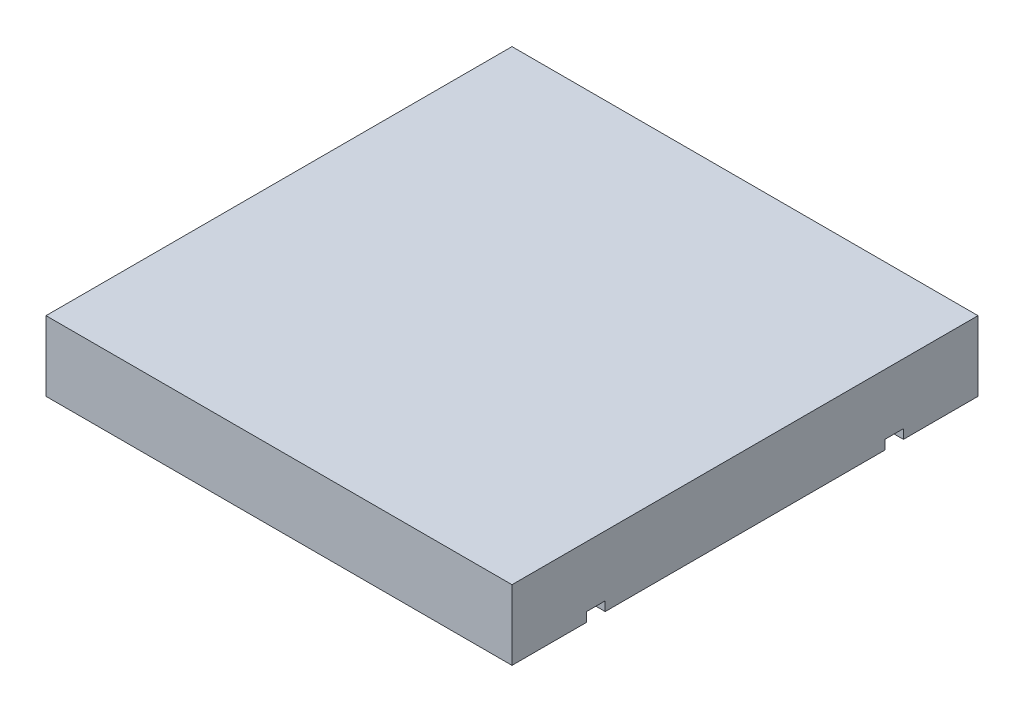
from build123d import *

# Parameters (mm, degrees)
ESBO_O1_W                = 1000
ESBO_O1_H                = 1000
RESSALTO_EXTRUS_O1_DEPTH = 150
ESBO_O2_W                = 40
ESBO_O2_H                = 40
CORTE_EXTRUS_O1_DEPTH    = 1001


with BuildPart() as part:
    # Esboço1 → Ressalto-extrusão1 (new body)
    with BuildSketch(Plane(origin=(0, 0, 0), x_dir=(1, 0, 0), z_dir=(0, 1, 0))):
        Rectangle(ESBO_O1_W, ESBO_O1_H)
    extrude(amount=RESSALTO_EXTRUS_O1_DEPTH)

    # Esboço2 → Corte-extrusão1 (cut, through all)
    with BuildSketch(Plane.ZY.offset(500)):
        with Locations((320, 0)):
            Rectangle(ESBO_O2_W, ESBO_O2_H)
        with Locations((-320, 0)):
            Rectangle(ESBO_O2_W, ESBO_O2_H)
    extrude(amount=-CORTE_EXTRUS_O1_DEPTH, mode=Mode.SUBTRACT)


solid = part.part
